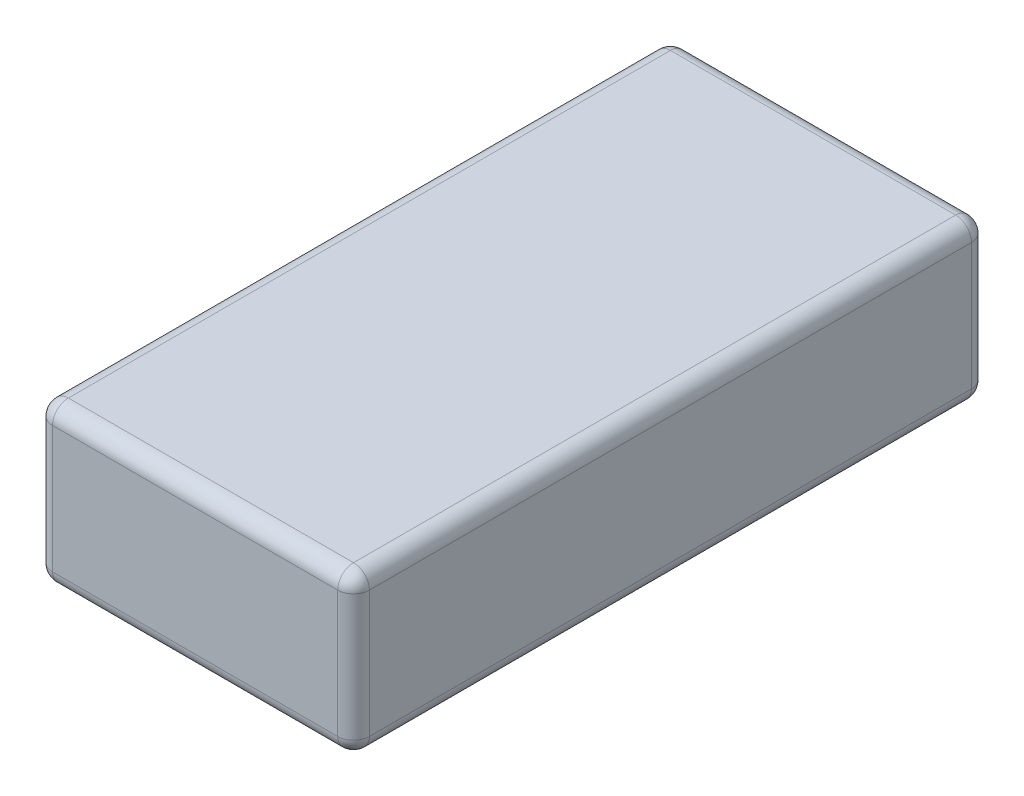
from build123d import *

# Parameters (mm, degrees)
SKETCH1_W           = 10
SKETCH1_H           = 20
BOSS_EXTRUDE1_DEPTH = 5
FILLET1_R           = 0.5


with BuildPart() as part:
    # Sketch1 → Boss-Extrude1 (new body)
    with BuildSketch(Plane(origin=(0, 0, 0), x_dir=(1, 0, 0), z_dir=(0, 1, 0))):
        Rectangle(SKETCH1_W, SKETCH1_H)
    extrude(amount=BOSS_EXTRUDE1_DEPTH)

    # Fillet1
    fillet1_edges = [part.edges().sort_by_distance(p)[0] for p in [
        (5, 5, 0),
        (0, 5, -10),
        (-5, 5, 0),
        (0, 0, -10),
        (5, 0, 0),
        (0, 0, 10),
        (-5, 0, 0),
        (-5, 2.5, -10),
        (5, 2.5, -10),
        (5, 2.5, 10),
        (-5, 2.5, 10),
        (0, 5, 10),
    ]]
    fillet(fillet1_edges, radius=FILLET1_R)


solid = part.part
